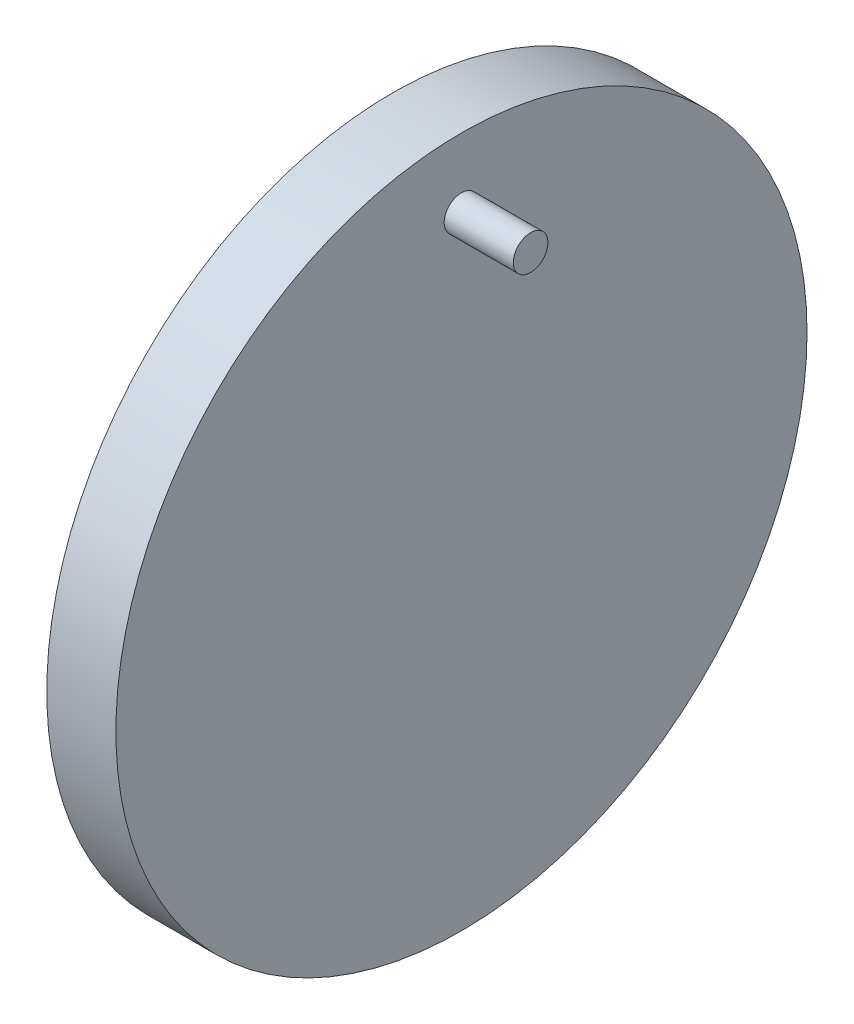
from build123d import *

# Parameters (mm, degrees)
SKETCH1_R           = 50
BOSS_EXTRUDE1_DEPTH = 10
SKETCH2_R           = 2.5
BOSS_EXTRUDE2_DEPTH = 10


with BuildPart() as part:
    # Sketch1 → Boss-Extrude1 (new body)
    with BuildSketch(Plane(origin=(0, 0, 0), x_dir=(0, 0, -1), z_dir=(1, 0, 0))):
        Circle(SKETCH1_R)
    extrude(amount=BOSS_EXTRUDE1_DEPTH)

    # Sketch2 → Boss-Extrude2 (add)
    with BuildSketch(Plane(origin=(10, 0, 0), x_dir=(0, 0, -1), z_dir=(1, 0, 0))):
        with Locations((0, 40)):
            Circle(SKETCH2_R)
    extrude(amount=BOSS_EXTRUDE2_DEPTH)


solid = part.part
